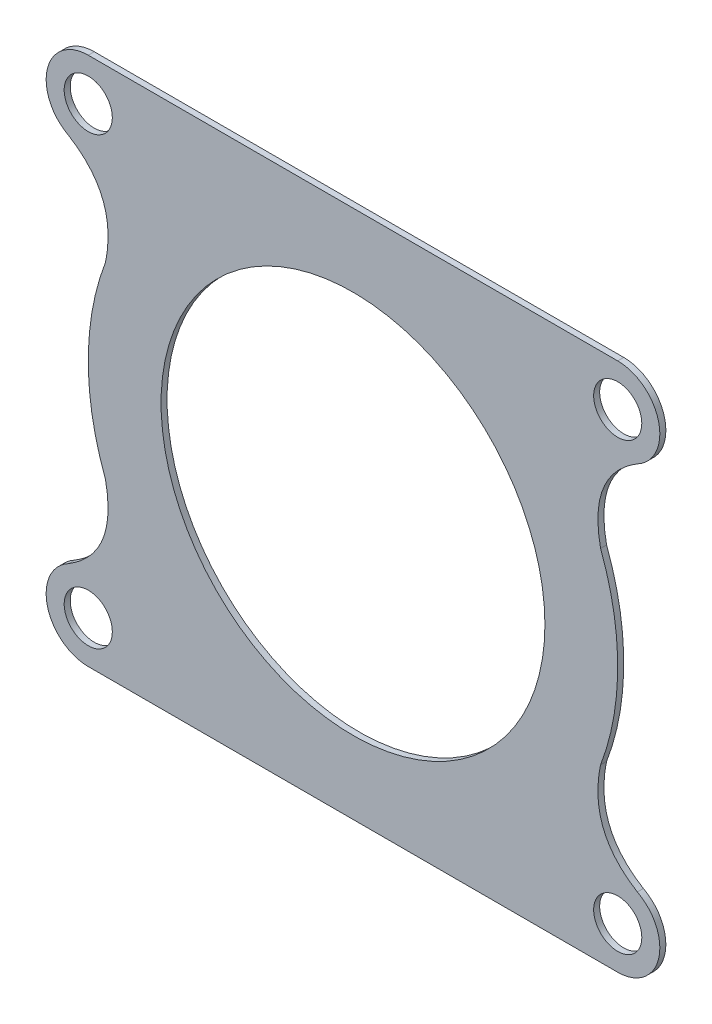
from build123d import *

# Parameters (mm, degrees)
SKETCH2_R           = 1
SKETCH2_R_2         = 7.975
BOSS_EXTRUDE1_DEPTH = 0.25


with BuildPart() as part:
    # Sketch2 → Boss-Extrude1 (new body)
    with BuildSketch(Plane.XY):
        with BuildLine():
            Line((-10.99049083, -10.599113396), (11.00950917, -10.599113396))
            ThreePointArc((11.00950917, -10.599113396), (12.70835196, -9.26915289), (11.825030389, -7.300751312))
            add(Edge.make_bspline(
                [(11.825030389, -7.300751312), (9.759593251, -6.043315053), (10.296923436, -3.493867271)],
                knots=[0, 0, 0, 1, 1, 1], degree=2))
            ThreePointArc((10.296923436, -3.493867271), (11.009509171, 0.400886603), (10.296923436, 4.295640477))
            add(Edge.make_bspline(
                [(10.296923436, 4.295640477), (9.75959325, 6.845088261), (11.825030389, 8.102524521)],
                knots=[0, 0, 0, 1, 1, 1], degree=2))
            ThreePointArc((11.825030389, 8.102524521), (12.70835196, 10.070926099), (11.00950917, 11.400886604))
            Line((11.00950917, 11.400886604), (-10.99049083, 11.400886604))
            ThreePointArc((-10.99049083, 11.400886604), (-12.689333619, 10.070926099), (-11.806012048, 8.102524521))
            add(Edge.make_bspline(
                [(-11.806012048, 8.102524521), (-9.740574911, 6.845088262), (-10.277905095, 4.29564048)],
                knots=[0, 0, 0, 1, 1, 1], degree=2))
            ThreePointArc((-10.277905095, 4.29564048), (-10.99049083, 0.400886606), (-10.277905095, -3.493867268))
            add(Edge.make_bspline(
                [(-10.277905095, -3.493867268), (-9.740574909, -6.043315053), (-11.806012048, -7.300751312)],
                knots=[0, 0, 0, 1, 1, 1], degree=2))
            ThreePointArc((-11.806012048, -7.300751312), (-12.689333619, -9.26915289), (-10.99049083, -10.599113396))
        make_face()
        with Locations((11.00950917, 9.650886604)):
            Circle(SKETCH2_R, mode=Mode.SUBTRACT)
        with Locations((-10.99049083, 9.650886604)):
            Circle(SKETCH2_R, mode=Mode.SUBTRACT)
        with Locations((11.00950917, -8.849113396)):
            Circle(SKETCH2_R, mode=Mode.SUBTRACT)
        with Locations((-10.99049083, -8.849113396)):
            Circle(SKETCH2_R, mode=Mode.SUBTRACT)
        with Locations((0.00950917, 0.400886604)):
            Circle(SKETCH2_R_2, mode=Mode.SUBTRACT)
    extrude(amount=BOSS_EXTRUDE1_DEPTH)


solid = part.part
